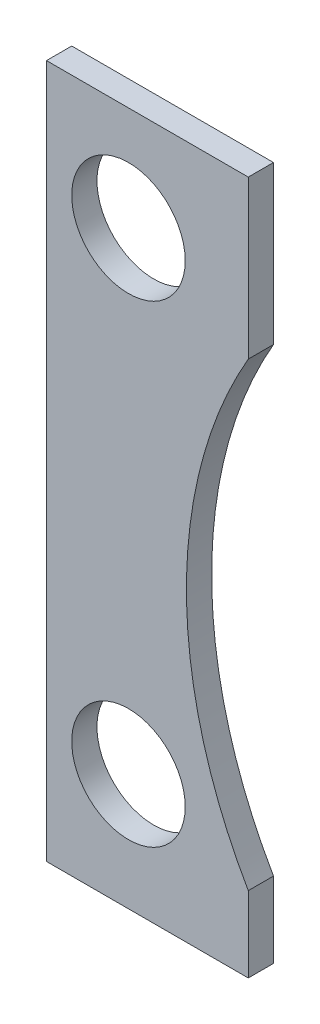
from build123d import *

# Parameters (mm, degrees)
Y_KSEKLIK_EKSTR_ZYON1_DEPTH = 2
IZIM2_R                     = 9
KES_EKSTR_ZYON1_DEPTH       = 5


with BuildPart() as part:
    # Çizim1 → Yükseklik-Ekstrüzyon1 (new body, symmetric)
    with BuildSketch(Plane.XY):
        with BuildLine():
            Line((0, 0), (0, 110))
            Line((0, 110), (32, 110))
            Line((32, 110), (32, 85))
            ThreePointArc((32, 85), (22.190316578, 48.5), (32, 12))
            Line((32, 12), (32, 0))
            Line((32, 0), (0, 0))
        make_face()
    extrude(amount=Y_KSEKLIK_EKSTR_ZYON1_DEPTH, both=True)

    # Çizim2 → Kes-Ekstrüzyon1 (cut, through all)
    with BuildSketch(Plane.XY.offset(2)):
        with Locations((13, 93.5)):
            Circle(IZIM2_R)
        with Locations((13, 18.5)):
            Circle(IZIM2_R)
    extrude(amount=-KES_EKSTR_ZYON1_DEPTH, mode=Mode.SUBTRACT)


solid = part.part
